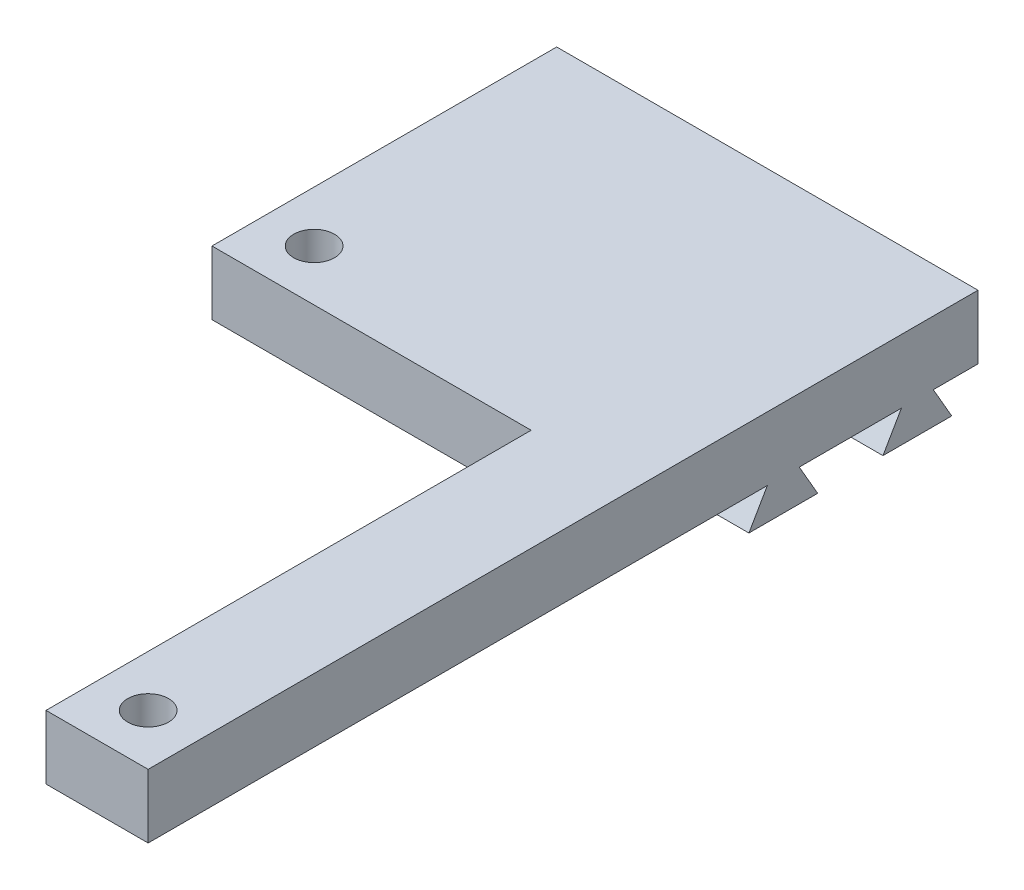
from build123d import *

# Parameters (mm, degrees)
BOSS_EXTRUDE1_DEPTH = 5
BOSS_EXTRUDE3_DEPTH = 33
SKETCH4_W           = 25
SKETCH4_H           = 5
BOSS_EXTRUDE4_DEPTH = 7
SKETCH5_W           = 8
SKETCH5_H           = 5
BOSS_EXTRUDE5_DEPTH = 5
SKETCH6_R           = 1.6
CUT_EXTRUDE1_DEPTH  = 8.5


with BuildPart() as part:
    # Sketch1 → Boss-Extrude1 (new body)
    with BuildSketch(Plane(origin=(0, 0, 0), x_dir=(1, 0, 0), z_dir=(0, 1, 0))):
        Polygon((-16.5, 10), (8.5, 10), (8.5, -30), (16.5, -30), (16.5, 30), (-16.5, 30), align=None)
    extrude(amount=BOSS_EXTRUDE1_DEPTH)

    # Sketch3 → Boss-Extrude3 (add)
    with BuildSketch(Plane.ZY.offset(16.5)):
        Polygon((-24, 0), (-26.5, 0), (-27.943375673, -2.5), (-22.556624327, -2.5), align=None)
        Polygon((-13.5, 0), (-16, 0), (-17.443375673, -2.5), (-12.056624327, -2.5), align=None)
    extrude(amount=-BOSS_EXTRUDE3_DEPTH)

    # Sketch4 → Boss-Extrude4 (add)
    with BuildSketch(Plane.XY.offset(-10)):
        with Locations((-4, 2.5)):
            Rectangle(SKETCH4_W, SKETCH4_H)
    extrude(amount=BOSS_EXTRUDE4_DEPTH)

    # Sketch5 → Boss-Extrude5 (add)
    with BuildSketch(Plane.XY.offset(30)):
        with Locations((12.5, 2.5)):
            Rectangle(SKETCH5_W, SKETCH5_H)
    extrude(amount=BOSS_EXTRUDE5_DEPTH)

    # Sketch6 → Cut-Extrude1 (cut, through all)
    with BuildSketch(Plane(origin=(0, 5, 0), x_dir=(1, 0, 0), z_dir=(0, 1, 0))):
        with Locations((-12.5, 7)):
            Circle(SKETCH6_R)
        with Locations((12.5, -31)):
            Circle(SKETCH6_R)
    extrude(amount=-CUT_EXTRUDE1_DEPTH, mode=Mode.SUBTRACT)


solid = part.part
